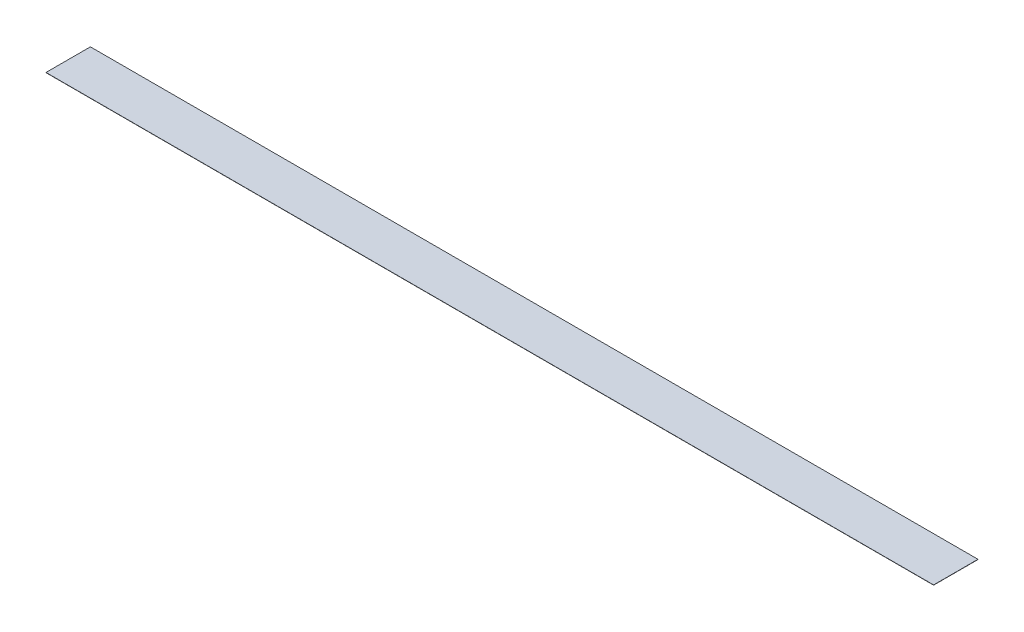
from build123d import *

# Parameters (mm, degrees)
SKETCH1_W           = 1016
SKETCH1_H           = 50.8
BOSS_EXTRUDE1_DEPTH = 0.254


with BuildPart() as part:
    # Sketch1 → Boss-Extrude1 (new body)
    with BuildSketch(Plane(origin=(0, 0, 0), x_dir=(1, 0, 0), z_dir=(0, 1, 0))):
        Rectangle(SKETCH1_W, SKETCH1_H)
    extrude(amount=BOSS_EXTRUDE1_DEPTH)


solid = part.part
